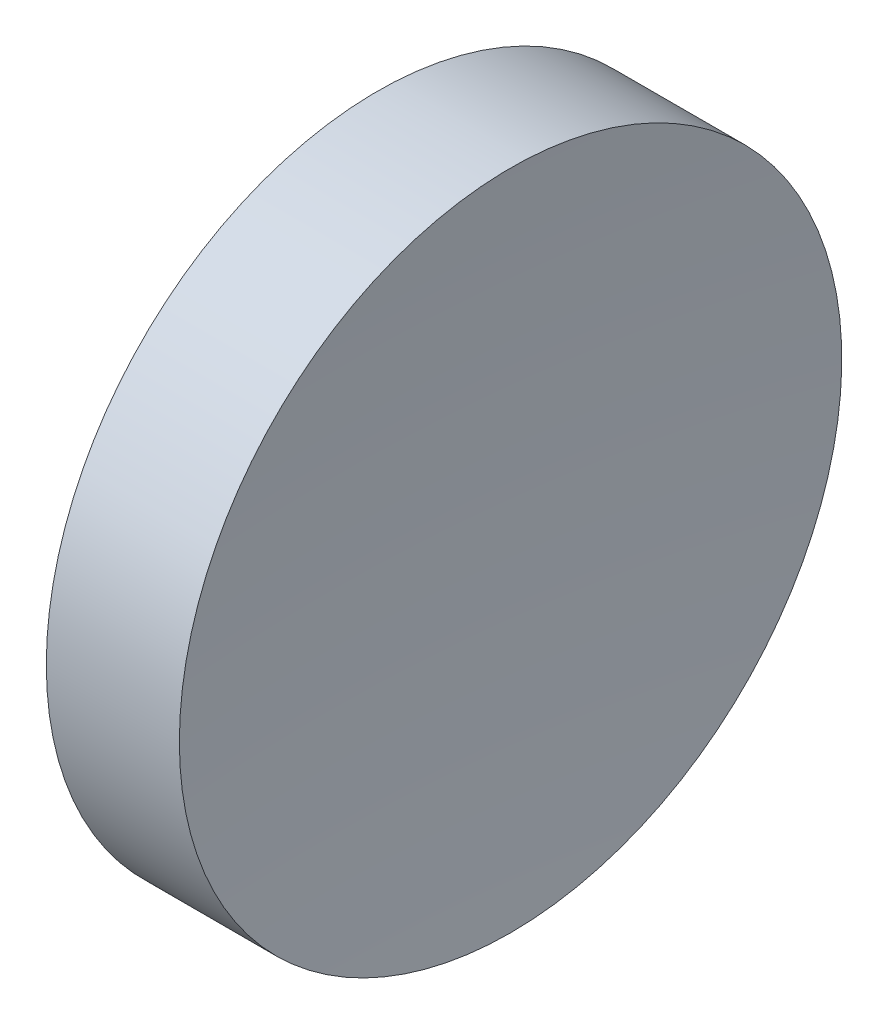
from build123d import *


with BuildPart() as part:
    # 草图1 → 旋转1 (revolve)
    with BuildSketch(Plane.XY, mode=Mode.PRIVATE) as revolve_1_sk:
        with BuildLine():
            Line((230.18531107, 138.756042247), (230.18531107, 163.756042247))
            Line((230.18531107, 163.756042247), (240.228797224, 163.756042247))
            ThreePointArc((240.228797224, 163.756042247), (239.446299678, 151.266926043), (239.185315802, 138.756042247))
            Line((239.185315802, 138.756042247), (230.18531107, 138.756042247))
        make_face()
    revolve(revolve_1_sk.sketch.rotate(Axis((217.970286004, 138.756042247, 0), (1, 0, 0)), 180), axis=Axis((217.970286004, 138.756042247, 0), (1, 0, 0)))  # turned: the seam where the file's is


solid = part.part
